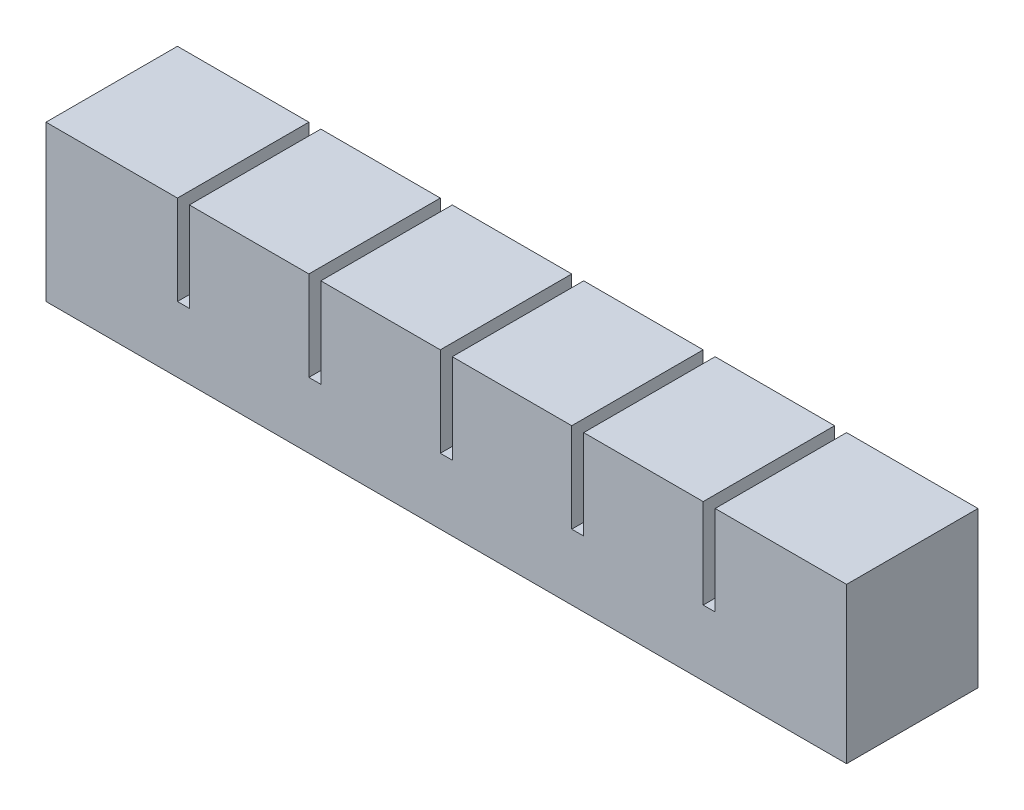
from build123d import *

# Parameters (mm, degrees)
SKETCH1_W           = 20
SKETCH1_H           = 20
BOSS_EXTRUDE1_DEPTH = 22
SKETCH2_W           = 12
SKETCH2_H           = 14
CUT_EXTRUDE1_DEPTH  = 16
SKETCH3_W           = 22
SKETCH3_H           = 5
BOSS_EXTRUDE2_DEPTH = 2
LPATTERN1_COUNT     = 6
LPATTERN1_PITCH     = 22
SKETCH4_W           = 22
SKETCH4_H           = 15
BOSS_EXTRUDE3_DEPTH = 2
SKETCH5_W           = 22
SKETCH5_H           = 20
BOSS_EXTRUDE4_DEPTH = 2
SKETCH6_W           = 122
SKETCH6_H           = 2
CUT_EXTRUDE2_DEPTH  = 2
SKETCH7_W           = 134
SKETCH7_H           = 22
BOSS_EXTRUDE5_DEPTH = 6


with BuildPart() as part:
    # Sketch1 → Boss-Extrude1 (new body)
    with BuildSketch(Plane.XY):
        with Locations((10, 10)):
            Rectangle(SKETCH1_W, SKETCH1_H)
    extrude(amount=BOSS_EXTRUDE1_DEPTH)

    # Sketch2 → Cut-Extrude1 (cut)
    with BuildSketch(Plane.XZ):
        with Locations((10, 11)):
            Rectangle(SKETCH2_W, SKETCH2_H)
    extrude(amount=-CUT_EXTRUDE1_DEPTH, mode=Mode.SUBTRACT)

    # Sketch3 → Boss-Extrude2 (add)
    with BuildSketch(Plane(origin=(20, 0, 0), x_dir=(0, 0, -1), z_dir=(1, 0, 0))):
        with Locations((-11, 2.5)):
            Rectangle(SKETCH3_W, SKETCH3_H)
    extrude(amount=BOSS_EXTRUDE2_DEPTH)


with BuildPart() as lpattern1_1:
    # LPattern1: pattern copy
    add(part.part.moved(Location(Vector(1, 0, 0) * (1 * LPATTERN1_PITCH))))


with BuildPart() as lpattern1_2:
    # LPattern1: pattern copy
    add(part.part.moved(Location(Vector(1, 0, 0) * (2 * LPATTERN1_PITCH))))


with BuildPart() as lpattern1_3:
    # LPattern1: pattern copy
    add(part.part.moved(Location(Vector(1, 0, 0) * (3 * LPATTERN1_PITCH))))


with BuildPart() as lpattern1_4:
    # LPattern1: pattern copy
    add(part.part.moved(Location(Vector(1, 0, 0) * (4 * LPATTERN1_PITCH))))


with BuildPart() as lpattern1_5:
    # LPattern1: pattern copy
    add(part.part.moved(Location(Vector(1, 0, 0) * (5 * LPATTERN1_PITCH))))


with BuildPart() as part_1:
    add(part.part)

    # Combine1: union LPattern1_1, LPattern1_2, LPattern1_3, LPattern1_4, LPattern1_5
    add(lpattern1_1.part)
    add(lpattern1_2.part)
    add(lpattern1_3.part)
    add(lpattern1_4.part)
    add(lpattern1_5.part)

    # Sketch4 → Boss-Extrude3 (add)
    with BuildSketch(Plane(origin=(130, 0, 0), x_dir=(0, 0, -1), z_dir=(1, 0, 0))):
        with Locations((-11, 12.5)):
            Rectangle(SKETCH4_W, SKETCH4_H)
    extrude(amount=BOSS_EXTRUDE3_DEPTH)

    # Sketch5 → Boss-Extrude4 (add)
    with BuildSketch(Plane.ZY):
        with Locations((11, 10)):
            Rectangle(SKETCH5_W, SKETCH5_H)
    extrude(amount=BOSS_EXTRUDE4_DEPTH)

    # Sketch6 → Cut-Extrude2 (cut)
    with BuildSketch(Plane(origin=(0, 0, 0), x_dir=(-1, 0, 0), z_dir=(0, -1, 0))):
        with Locations((-65, -11)):
            Rectangle(SKETCH6_W, SKETCH6_H)
    extrude(amount=-CUT_EXTRUDE2_DEPTH, mode=Mode.SUBTRACT)

    # Sketch7 → Boss-Extrude5 (add)
    with BuildSketch(Plane.XZ):
        with Locations((65, 11)):
            Rectangle(SKETCH7_W, SKETCH7_H)
    extrude(amount=BOSS_EXTRUDE5_DEPTH)


solid = part_1.part
